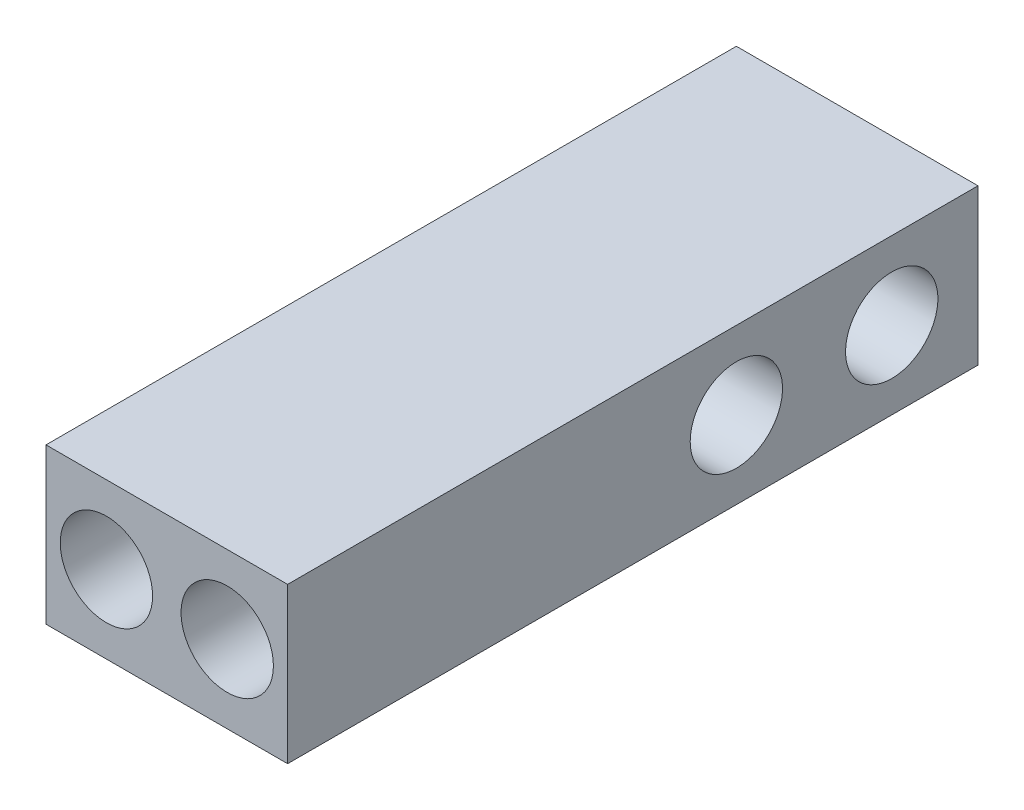
from build123d import *

# Parameters (mm, degrees)
CROQUIS1_W              = 14
CROQUIS1_H              = 40
SALIENTE_EXTRUIR1_DEPTH = 9
CROQUIS3_R              = 2.675
CORTAR_EXTRUIR2_DEPTH   = 15
CROQUIS4_R              = 2.675
CORTAR_EXTRUIR3_DEPTH   = 15


with BuildPart() as part:
    # Croquis1 → Saliente-Extruir1 (new body)
    with BuildSketch(Plane(origin=(0, 0, 0), x_dir=(1, 0, 0), z_dir=(0, 1, 0))):
        Rectangle(CROQUIS1_W, CROQUIS1_H)
    extrude(amount=SALIENTE_EXTRUIR1_DEPTH)

    # Croquis3 → Cortar-Extruir2 (cut)
    with BuildSketch(Plane.XY.offset(20)):
        with Locations((-3.5, 4.5)):
            Circle(CROQUIS3_R)
        with Locations((3.5, 4.5)):
            Circle(CROQUIS3_R)
    extrude(amount=-CORTAR_EXTRUIR2_DEPTH, mode=Mode.SUBTRACT)

    # Croquis4 → Cortar-Extruir3 (cut, through all)
    with BuildSketch(Plane.ZY.offset(7)):
        with Locations((-15, 4.5)):
            Circle(CROQUIS4_R)
        with Locations((-6, 4.5)):
            Circle(CROQUIS4_R)
    extrude(amount=-CORTAR_EXTRUIR3_DEPTH, mode=Mode.SUBTRACT)


solid = part.part
